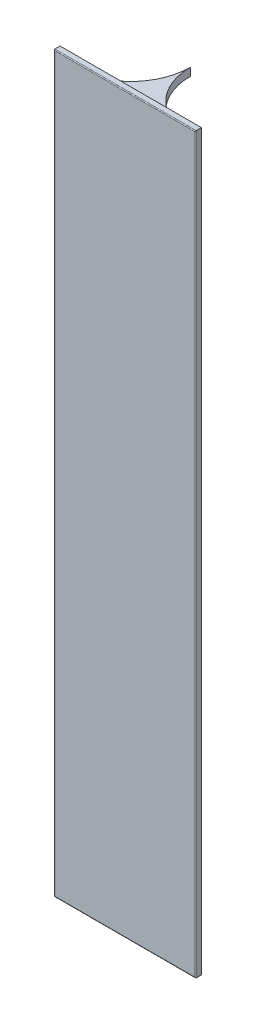
from build123d import *

# Parameters (mm, degrees)
SKETCH1_W           = 35.6
SKETCH1_H           = 184.8
BOSS_EXTRUDE1_DEPTH = 1.5
FILLET1_R           = 0.2
BOSS_EXTRUDE2_DEPTH = 2


with BuildPart() as part:
    # Sketch1 → Boss-Extrude1 (new body)
    with BuildSketch(Plane.XY):
        Rectangle(SKETCH1_W, SKETCH1_H)
    extrude(amount=BOSS_EXTRUDE1_DEPTH)

    # Fillet1
    fillet1_edges = [part.edges().sort_by_distance(p)[0] for p in [
        (-17.8, 0, 1.5),
        (0, -92.4, 1.5),
        (17.8, 0, 1.5),
        (0, 92.4, 1.5),
    ]]
    fillet(fillet1_edges, radius=FILLET1_R)


with BuildPart() as body_2:
    # Sketch2 → Boss-Extrude2 (new body)
    with BuildSketch(Plane(origin=(0, 89.167036502, 0), x_dir=(1, 0, 0), z_dir=(0, 1, 0))):
        with BuildLine():
            Line((14.81369991, 0.001156969), (-14.81369991, 0.001156969))
            ThreePointArc((-14.81369991, 0.001156969), (-4.327734511, 4.459471108), (0, 15))
            ThreePointArc((0, 15), (4.327734511, 4.459471108), (14.81369991, 0.001156969))
        make_face()
    extrude(amount=-BOSS_EXTRUDE2_DEPTH)


solid = Compound([part.part, body_2.part])
